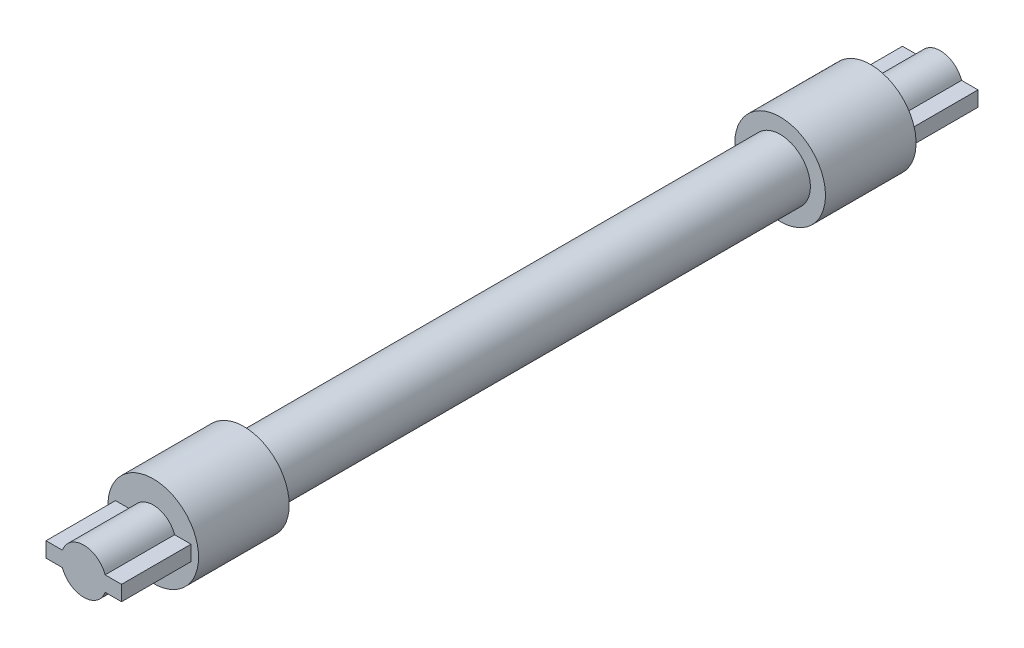
from build123d import *

# Parameters (mm, degrees)
SKETCH1_R           = 40
BOSS_EXTRUDE1_DEPTH = 710
SKETCH2_R           = 60
BOSS_EXTRUDE2_DEPTH = 120
SKETCH3_R           = 60
BOSS_EXTRUDE3_DEPTH = 120
BOSS_EXTRUDE4_DEPTH = 92
BOSS_EXTRUDE5_DEPTH = 92


with BuildPart() as part:
    # Sketch1 → Boss-Extrude1 (new body)
    with BuildSketch(Plane.XY):
        Circle(SKETCH1_R)
    extrude(amount=BOSS_EXTRUDE1_DEPTH)

    # Sketch2 → Boss-Extrude2 (add)
    with BuildSketch(Plane.XY.offset(710)):
        Circle(SKETCH2_R)
    extrude(amount=BOSS_EXTRUDE2_DEPTH)

    # Sketch3 → Boss-Extrude3 (add)
    with BuildSketch(Plane(origin=(0, 0, 0), x_dir=(-1, 0, 0), z_dir=(0, 0, -1))):
        Circle(SKETCH3_R)
    extrude(amount=BOSS_EXTRUDE3_DEPTH)

    # Sketch4 → Boss-Extrude4 (add)
    with BuildSketch(Plane.XY.offset(830)):
        with BuildLine():
            Line((-28.284271247, 10), (-50, 10))
            Line((-50, 10), (-50, -10))
            Line((-50, -10), (-28.284271247, -10))
            ThreePointArc((-28.284271247, -10), (-30, 0), (-28.284271247, 10))
        make_face()
        with BuildLine():
            ThreePointArc((28.284271247, 10), (0, 30), (-28.284271247, 10))
            Line((-28.284271247, 10), (28.284271247, 10))
        make_face()
        with BuildLine():
            Line((28.284271247, 10), (-28.284271247, 10))
            ThreePointArc((-28.284271247, 10), (-30, 0), (-28.284271247, -10))
            Line((-28.284271247, -10), (28.284271247, -10))
            ThreePointArc((28.284271247, -10), (29.56795679, -5.073059362), (30, 0))
            ThreePointArc((30, 0), (29.56795679, 5.073059362), (28.284271247, 10))
        make_face()
        with BuildLine():
            Line((28.284271247, -10), (-28.284271247, -10))
            ThreePointArc((-28.284271247, -10), (0, -30), (28.284271247, -10))
        make_face()
        with BuildLine():
            Line((50, 10), (28.284271247, 10))
            ThreePointArc((28.284271247, 10), (29.56795679, 5.073059362), (30, 0))
            ThreePointArc((30, 0), (29.56795679, -5.073059362), (28.284271247, -10))
            Line((28.284271247, -10), (50, -10))
            Line((50, -10), (50, 10))
        make_face()
    extrude(amount=BOSS_EXTRUDE4_DEPTH)

    # Sketch5 → Boss-Extrude5 (add)
    with BuildSketch(Plane(origin=(0, 0, -120), x_dir=(-1, 0, 0), z_dir=(0, 0, -1))):
        with BuildLine():
            Line((-28.284271247, 10), (28.284271247, 10))
            ThreePointArc((28.284271247, 10), (0, 30), (-28.284271247, 10))
        make_face()
        with BuildLine():
            Line((-50, -10), (-28.284271247, -10))
            ThreePointArc((-28.284271247, -10), (-30, 0), (-28.284271247, 10))
            Line((-28.284271247, 10), (-50, 10))
            Line((-50, 10), (-50, -10))
        make_face()
        with BuildLine():
            Line((-28.284271247, -10), (28.284271247, -10))
            ThreePointArc((28.284271247, -10), (29.56795679, -5.073059362), (30, 0))
            ThreePointArc((30, 0), (29.56795679, 5.073059362), (28.284271247, 10))
            Line((28.284271247, 10), (-28.284271247, 10))
            ThreePointArc((-28.284271247, 10), (-30, 0), (-28.284271247, -10))
        make_face()
        with BuildLine():
            ThreePointArc((-28.284271247, -10), (0, -30), (28.284271247, -10))
            Line((28.284271247, -10), (-28.284271247, -10))
        make_face()
        with BuildLine():
            Line((28.284271247, -10), (50, -10))
            Line((50, -10), (50, 10))
            Line((50, 10), (28.284271247, 10))
            ThreePointArc((28.284271247, 10), (29.56795679, 5.073059362), (30, 0))
            ThreePointArc((30, 0), (29.56795679, -5.073059362), (28.284271247, -10))
        make_face()
    extrude(amount=BOSS_EXTRUDE5_DEPTH)


solid = part.part
